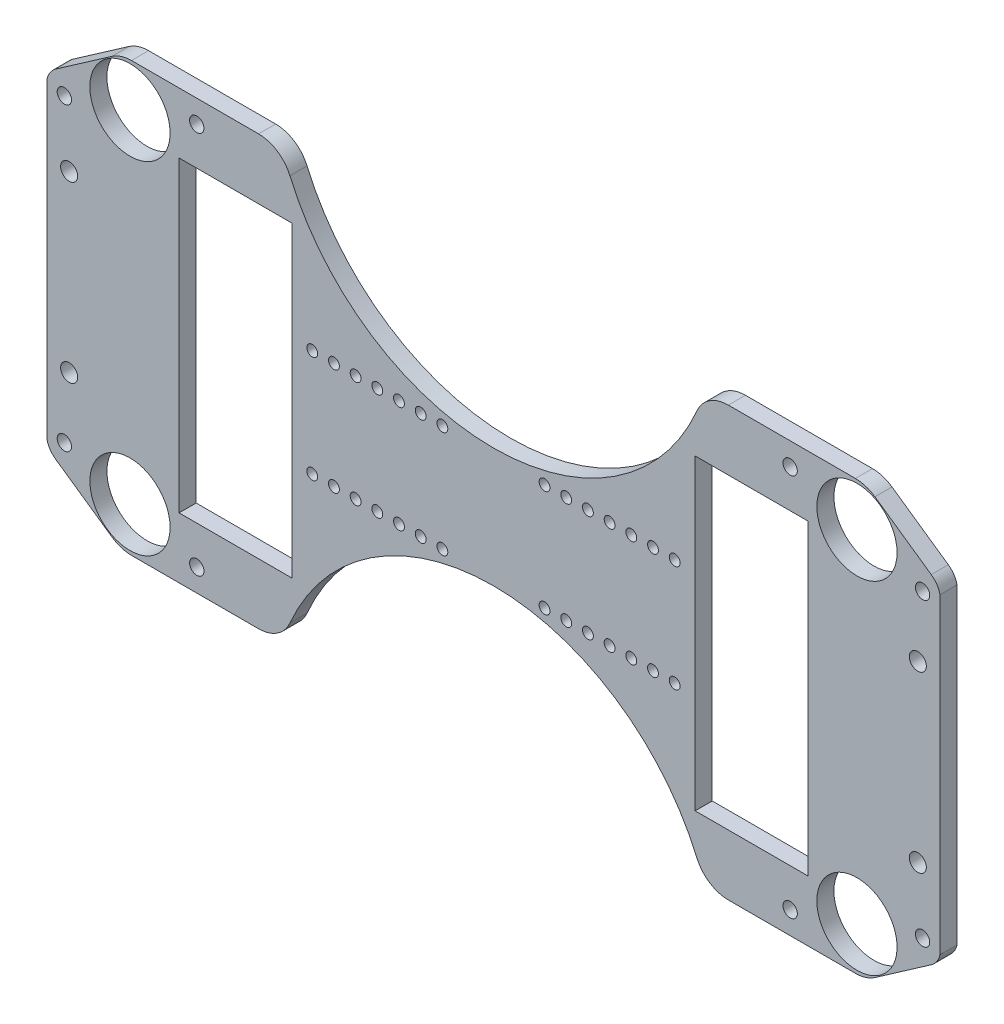
from build123d import *

# Parameters (mm, degrees)
SKETCH1_W           = 261.5
SKETCH1_H           = 125.5
SKETCH1_R           = 2.5
SKETCH1_R_2         = 1.59
SKETCH1_R_3         = 2.1
SKETCH1_R_4         = 11.75
SKETCH1_W_2         = 33
SKETCH1_H_2         = 90
BOSS_EXTRUDE1_DEPTH = 5
CUT_EXTRUDE1_DEPTH  = 10
FILLET1_R           = 10
FILLET2_R           = 10


with BuildPart() as part:
    # Sketch1 → Boss-Extrude1 (new body)
    with BuildSketch(Plane.XY):
        with Locations((130.75, -62.75)):
            Rectangle(SKETCH1_W, SKETCH1_H)
        with Locations((255, -37.25)):
            Circle(SKETCH1_R, mode=Mode.SUBTRACT)
        with Locations((255, -88.25)):
            Circle(SKETCH1_R, mode=Mode.SUBTRACT)
        with Locations((183.81, -47.125)):
            Circle(SKETCH1_R_2, mode=Mode.SUBTRACT)
        with Locations((164.76, -78.375)):
            Circle(SKETCH1_R_2, mode=Mode.SUBTRACT)
        with Locations((152.06, -78.375)):
            Circle(SKETCH1_R_2, mode=Mode.SUBTRACT)
        with Locations((43.875030639, -118.888854871)):
            Circle(SKETCH1_R_3, mode=Mode.SUBTRACT)
        with Locations((183.81, -78.375)):
            Circle(SKETCH1_R_2, mode=Mode.SUBTRACT)
        with Locations((145.71, -47.125)):
            Circle(SKETCH1_R_2, mode=Mode.SUBTRACT)
        with Locations((158.41, -47.125)):
            Circle(SKETCH1_R_2, mode=Mode.SUBTRACT)
        with Locations((171.11, -47.125)):
            Circle(SKETCH1_R_2, mode=Mode.SUBTRACT)
        with Locations((145.71, -78.375)):
            Circle(SKETCH1_R_2, mode=Mode.SUBTRACT)
        with Locations((158.41, -78.375)):
            Circle(SKETCH1_R_2, mode=Mode.SUBTRACT)
        with Locations((171.11, -78.375)):
            Circle(SKETCH1_R_2, mode=Mode.SUBTRACT)
        with Locations((84.04, -78.375)):
            Circle(SKETCH1_R_2, mode=Mode.SUBTRACT)
        with Locations((96.74, -78.375)):
            Circle(SKETCH1_R_2, mode=Mode.SUBTRACT)
        with Locations((109.44, -78.375)):
            Circle(SKETCH1_R_2, mode=Mode.SUBTRACT)
        with Locations((84.04, -47.125)):
            Circle(SKETCH1_R_2, mode=Mode.SUBTRACT)
        with Locations((96.74, -47.125)):
            Circle(SKETCH1_R_2, mode=Mode.SUBTRACT)
        with Locations((109.44, -47.125)):
            Circle(SKETCH1_R_2, mode=Mode.SUBTRACT)
        with Locations((90.39, -78.375)):
            Circle(SKETCH1_R_2, mode=Mode.SUBTRACT)
        with Locations((103.09, -78.375)):
            Circle(SKETCH1_R_2, mode=Mode.SUBTRACT)
        with Locations((115.79, -78.375)):
            Circle(SKETCH1_R_2, mode=Mode.SUBTRACT)
        with Locations((90.39, -47.125)):
            Circle(SKETCH1_R_2, mode=Mode.SUBTRACT)
        with Locations((103.09, -47.125)):
            Circle(SKETCH1_R_2, mode=Mode.SUBTRACT)
        with Locations((115.79, -47.125)):
            Circle(SKETCH1_R_2, mode=Mode.SUBTRACT)
        with Locations((77.69, -78.375)):
            Circle(SKETCH1_R_2, mode=Mode.SUBTRACT)
        with Locations((5.1, -106.71894941)):
            Circle(SKETCH1_R_3, mode=Mode.SUBTRACT)
        with Locations((24.315775518, -112.75)):
            Circle(SKETCH1_R_4, mode=Mode.SUBTRACT)
        with Locations((256.4, -106.71894941)):
            Circle(SKETCH1_R_3, mode=Mode.SUBTRACT)
        with Locations((77.69, -47.125)):
            Circle(SKETCH1_R_2, mode=Mode.SUBTRACT)
        with Locations((6.5, -88.25)):
            Circle(SKETCH1_R, mode=Mode.SUBTRACT)
        with Locations((6.5, -37.25)):
            Circle(SKETCH1_R, mode=Mode.SUBTRACT)
        with Locations((237.184224482, -112.75)):
            Circle(SKETCH1_R_4, mode=Mode.SUBTRACT)
        with Locations((217.624969361, -118.888854871)):
            Circle(SKETCH1_R_3, mode=Mode.SUBTRACT)
        with Locations((152.06, -47.125)):
            Circle(SKETCH1_R_2, mode=Mode.SUBTRACT)
        with Locations((164.76, -47.125)):
            Circle(SKETCH1_R_2, mode=Mode.SUBTRACT)
        with Locations((177.46, -47.125)):
            Circle(SKETCH1_R_2, mode=Mode.SUBTRACT)
        with Locations((177.46, -78.375)):
            Circle(SKETCH1_R_2, mode=Mode.SUBTRACT)
        with Locations((256.4, -18.78105059)):
            Circle(SKETCH1_R_3, mode=Mode.SUBTRACT)
        with Locations((237.184224482, -12.75)):
            Circle(SKETCH1_R_4, mode=Mode.SUBTRACT)
        with Locations((217.624969361, -6.611145129)):
            Circle(SKETCH1_R_3, mode=Mode.SUBTRACT)
        with Locations((5.1, -18.78105059)):
            Circle(SKETCH1_R_3, mode=Mode.SUBTRACT)
        with Locations((43.875030639, -6.611145129)):
            Circle(SKETCH1_R_3, mode=Mode.SUBTRACT)
        with Locations((24.315775518, -12.75)):
            Circle(SKETCH1_R_4, mode=Mode.SUBTRACT)
        with Locations((206.31, -62.75)):
            Rectangle(SKETCH1_W_2, SKETCH1_H_2, mode=Mode.SUBTRACT)
        with Locations((55.19, -62.75)):
            Rectangle(SKETCH1_W_2, SKETCH1_H_2, mode=Mode.SUBTRACT)
    extrude(amount=BOSS_EXTRUDE1_DEPTH)

    # Sketch19 → Cut-Extrude1 (cut)
    with BuildSketch(Plane.XY.offset(5)):
        with BuildLine():
            Line((2.554773747, -112.220106382), (21.626568954, -125.5))
            Line((21.626568954, -125.5), (0, -125.5))
            Line((0, -125.5), (0, -108.394901529))
            ThreePointArc((0, -108.394901529), (0.915789995, -110.549006894), (2.554773747, -112.220106382))
        make_face()
        with BuildLine():
            Line((239.873431046, -125.5), (261.5, -125.5))
            Line((261.5, -125.5), (261.5, -108.394901529))
            ThreePointArc((261.5, -108.394901529), (260.584210005, -110.549006894), (258.945226253, -112.220106382))
            Line((258.945226253, -112.220106382), (239.873431046, -125.5))
        make_face()
        with BuildLine():
            Line((258.945226253, -13.279893618), (239.873431046, 0))
            Line((239.873431046, 0), (261.5, 0))
            Line((261.5, 0), (261.5, -17.105098471))
            ThreePointArc((261.5, -17.105098471), (260.584210005, -14.950993106), (258.945226253, -13.279893618))
        make_face()
        with BuildLine():
            Line((21.626568954, 0), (0, 0))
            Line((0, 0), (0, -17.105098471))
            ThreePointArc((0, -17.105098471), (0.915789995, -14.950993106), (2.554773747, -13.279893618))
            Line((2.554773747, -13.279893618), (21.626568954, 0))
        make_face()
        with BuildLine():
            ThreePointArc((68.905141109, -125.5), (130.75, -209.960536663), (192.594858891, -125.5))
            ThreePointArc((192.594858891, -125.5), (130.75, -80.215104564), (68.905141109, -125.5))
        make_face()
        with BuildLine():
            ThreePointArc((192.594858891, 0), (130.75, -45.284895436), (68.905141109, 0))
            ThreePointArc((68.905141109, 0), (130.75, 84.460536663), (192.594858891, 0))
        make_face()
    extrude(amount=-CUT_EXTRUDE1_DEPTH, mode=Mode.SUBTRACT)

    # Fillet1
    fillet1_edges = [part.edges().sort_by_distance(p)[0] for p in [
        (68.905141109, 0, 2.5),
        (192.594858891, 0, 2.5),
        (192.594858891, -125.5, 2.5),
        (68.905141109, -125.5, 2.5),
    ]]
    fillet(fillet1_edges, radius=FILLET1_R)

    # Fillet2
    fillet2_edges = [part.edges().sort_by_distance(p)[0] for p in [
        (239.873431046, 0, 2.5),
        (21.626568954, 0, 2.5),
        (21.626568954, -125.5, 2.5),
        (239.873431046, -125.5, 2.5),
    ]]
    fillet(fillet2_edges, radius=FILLET2_R)


solid = part.part
